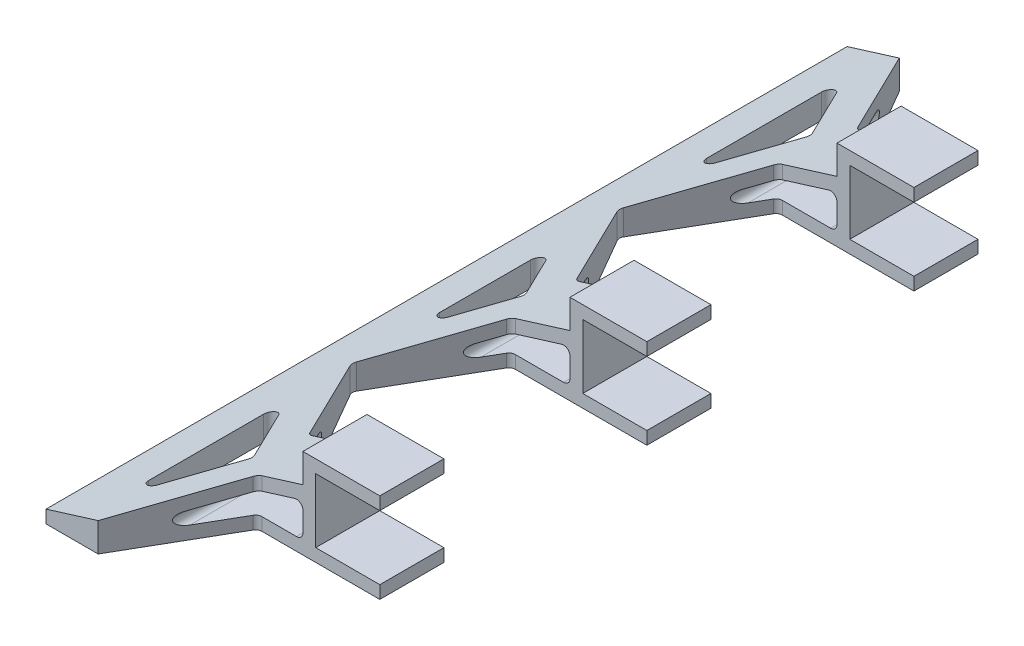
from build123d import *

# Parameters (mm, degrees)
SKETCH_1_W          = 250
SKETCH_1_H          = 4
EXTRUDE_1_DEPTH     = 20
EXTRUDE_1_2_DEPTH   = 20
SKETCH_2_W          = 250
SKETCH_2_H          = 28
EXTRUDE_2_DEPTH     = 4
SKETCH_3_W          = 250
SKETCH_3_H          = 4
EXTRUDE_3_DEPTH     = 48.5
EXTRUDE_4_DEPTH     = 250
CUT_EXTRUDE_1_DEPTH = 55
FILLET_1_R          = 2
CUT_EXTRUDE_2_DEPTH = 250


with BuildPart() as part:
    # 草图1 → 凸台-拉伸1 (new body)
    with BuildSketch(Plane(origin=(0, 0, 0), x_dir=(0, 0, -1), z_dir=(1, 0, 0))):
        with Locations((84.36416185, 14.963552055)):
            Rectangle(SKETCH_1_W, SKETCH_1_H)
    extrude(amount=EXTRUDE_1_DEPTH)



with BuildPart() as body_2:
    # 草图1 → Extrude 1 2 (new body)
    with BuildSketch(Plane(origin=(0, 0, 0), x_dir=(0, 0, -1), z_dir=(1, 0, 0))):
        with Locations((84.36416185, -9.036447945)):
            Rectangle(SKETCH_1_W, SKETCH_1_H)
    extrude(amount=EXTRUDE_1_2_DEPTH)


with BuildPart() as part_1:
    add(part.part)

    add(body_2.part)  # 凸台-拉伸2 merges body 2
    # 草图2 → 凸台-拉伸2 (add)
    with BuildSketch(Plane.ZY):
        with Locations((-84.36416185, 2.963552055)):
            Rectangle(SKETCH_2_W, SKETCH_2_H)
    extrude(amount=EXTRUDE_2_DEPTH)

    # 草图3 → 凸台-拉伸3 (add)
    with BuildSketch(Plane.ZY.offset(4)):
        with Locations((-84.36416185, -9.036447945)):
            Rectangle(SKETCH_3_W, SKETCH_3_H)
    extrude(amount=EXTRUDE_3_DEPTH)

    # 草图5 → 凸台-拉伸4 (add)
    with BuildSketch(Plane.XY.offset(40.63583815)):
        Polygon((-4, -7.036447945), (-52.5, -7.036447945), (-4, 7.963552055), align=None)
    extrude(amount=-EXTRUDE_4_DEPTH)

    # 草图7 → 切除-拉伸1 (cut)
    with BuildSketch(Plane(origin=(0, 16.963552055, 0), x_dir=(1, 0, 0), z_dir=(0, 1, 0))):
        Polygon((-36.220043801, 209.36416185), (-17.937285277, 177.697495183), (20, 177.697495183), (20, 209.36416185), align=None)
        Polygon((20, 157.697495183), (-22.217241476, 157.697495183), (-40.5, 126.030828516), (-22.217241476, 94.36416185), (20, 94.36416185), align=None)
        Polygon((-40.5, 196.77726344), (-40.5, 146.030828516), (-25.850766068, 171.404045978), align=None)
        Polygon((-40.5, 106.030828516), (-27.990744168, 84.36416185), (-40.5, 84.36416185), align=None)
    cut_extrude_1 = extrude(amount=-CUT_EXTRUDE_1_DEPTH, mode=Mode.SUBTRACT)

    # 镜向1: 切除-拉伸1 across plane
    add(cut_extrude_1.mirror(Plane(origin=(0, 0, -84.36416185), x_dir=(1, 0, 0), z_dir=(0, 0, -1))), mode=Mode.SUBTRACT)

    # 圆角1
    fillet_1_edges = [part_1.edges().sort_by_distance(p)[0] for p in [
        (-22.217241476, -4.353547142, -94.36416185),
        (-40.5, -7.180777842, -126.030828516),
        (-22.217241476, -4.353547142, -157.697495183),
        (-40.5, -7.180777842, -106.030828516),
        (-27.990744168, -5.246356837, -84.36416185),
        (-17.937285277, -3.691698245, -177.697495183),
        (-25.850766068, -4.915432388, 2.675722279),
        (-40.5, -7.180777842, 28.048939741),
        (-40.5, -7.180777842, -22.697495183),
        (-22.217241476, -4.353547142, -11.030828516),
        (-40.5, -7.180777842, -42.697495183),
        (-22.217241476, -4.353547142, -74.36416185),
        (-40.5, -7.180777842, -62.697495183),
        (-17.937285277, -3.691698245, 8.969171484),
        (-40.5, -7.180777842, -196.77726344),
        (-25.850766068, -4.915432388, -171.404045978),
        (-40.5, -7.180777842, -146.030828516),
    ]]
    fillet(fillet_1_edges, radius=FILLET_1_R)

    # 草图8 → 切除-拉伸2 (cut)
    with BuildSketch(Plane(origin=(0, 0, -209.36416185), x_dir=(-1, 0, 0), z_dir=(0, 0, -1))):
        with BuildLine():
            Line((4, 1.064588398), (4, -5.036447945))
            ThreePointArc((4, -5.036447945), (4.585786438, -6.450661507), (6, -7.036447945))
            Line((6, -7.036447945), (25.726684176, -7.036447945))
            ThreePointArc((25.726684176, -7.036447945), (27.704234228, -5.33527196), (26.317623622, -3.125743737))
            Line((26.317623622, -3.125743737), (6.590939446, 2.975292607))
            ThreePointArc((6.590939446, 2.975292607), (4.812961435, 2.674227937), (4, 1.064588398))
        make_face()
    extrude(amount=-CUT_EXTRUDE_2_DEPTH, mode=Mode.SUBTRACT)


solid = part_1.part
